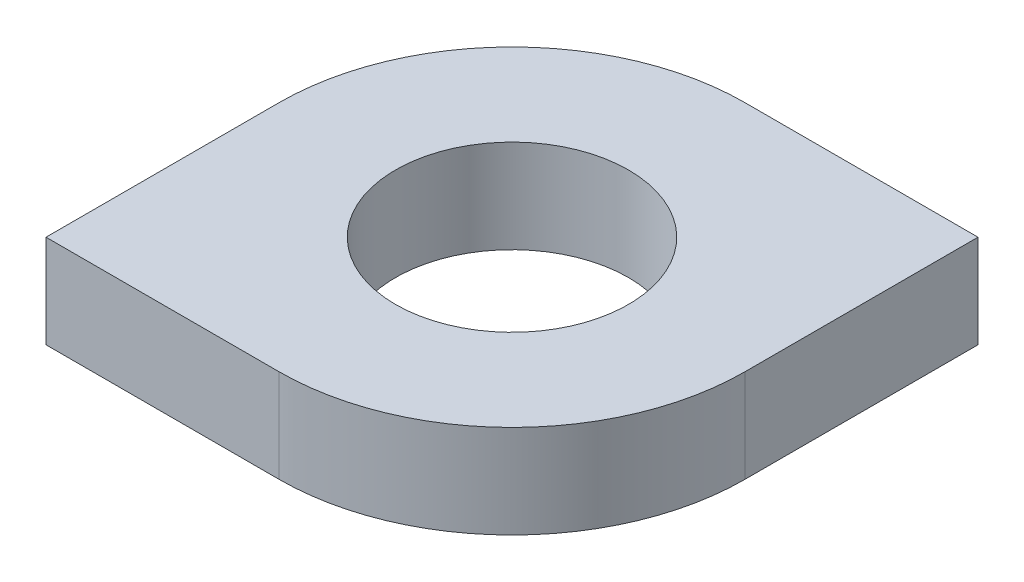
from build123d import *

# Parameters (mm, degrees)
EXTRUDE_1_DEPTH     = 4
SKETCH_2_R          = 5
CUT_EXTRUDE_1_DEPTH = 5


with BuildPart() as part:
    # Эскиз1 → Бобышка-Вытянуть1 (new body)
    with BuildSketch(Plane(origin=(0, 0, 0), x_dir=(1, 0, 0), z_dir=(0, 1, 0))):
        with BuildLine():
            Line((0, 0), (10, 0))
            ThreePointArc((10, 0), (17.071067812, 2.928932188), (20, 10))
            Line((20, 10), (20, 20))
            Line((20, 20), (10, 20))
            ThreePointArc((10, 20), (2.928932188, 17.071067812), (0, 10))
            Line((0, 10), (0, 0))
        make_face()
    extrude(amount=EXTRUDE_1_DEPTH)

    # Эскиз2 → Вырез-Вытянуть1 (cut, through all)
    with BuildSketch(Plane(origin=(0, 4, 0), x_dir=(1, 0, 0), z_dir=(0, 1, 0))):
        with Locations((10, 10)):
            Circle(SKETCH_2_R)
    extrude(amount=-CUT_EXTRUDE_1_DEPTH, mode=Mode.SUBTRACT)


solid = part.part
